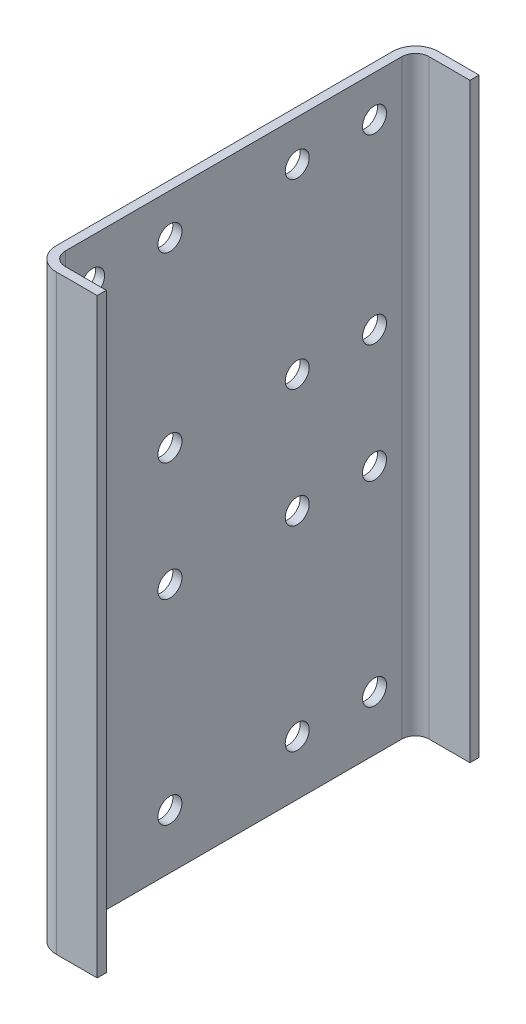
from build123d import *

# Parameters (mm, degrees)
BASE_EXTRUDE_THIN_DEPTH      = 196.85
BASE_EXTRUDE_THIN_DEPTH_BACK = 215.9
SKETCH3_R                    = 8.382
HOLES_DEPTH                  = 258.625377244


with BuildPart() as part:
    # Sketch1 → Base-Extrude-Thin (new, two sides)
    with BuildSketch(Plane(origin=(0, 0, 0), x_dir=(1, 0, 0), z_dir=(0, 1, 0))) as base_extrude_thin_sk:
        with BuildLine():
            Line((44.45, 133.35), (15.875, 133.35))
            ThreePointArc((15.875, 133.35), (4.649679849, 128.700320151), (0, 117.475))
            Line((0, 117.475), (0, 0))
            Line((0, 0), (0, -117.475))
            ThreePointArc((0, -117.475), (4.649679849, -128.700320151), (15.875, -133.35))
            Line((15.875, -133.35), (44.45, -133.35))
            Line((44.45, -133.35), (44.45, -127))
            Line((44.45, -127), (15.875, -127))
            ThreePointArc((15.875, -127), (9.139807909, -124.210192091), (6.35, -117.475))
            Line((6.35, -117.475), (6.35, 0))
            Line((6.35, 0), (6.35, 117.475))
            ThreePointArc((6.35, 117.475), (9.139807909, 124.210192091), (15.875, 127))
            Line((15.875, 127), (44.45, 127))
            Line((44.45, 127), (44.45, 133.35))
        make_face()
    extrude(amount=BASE_EXTRUDE_THIN_DEPTH)
    extrude(base_extrude_thin_sk.sketch, amount=-BASE_EXTRUDE_THIN_DEPTH_BACK)

    # Sketch3 (on Right Plane) → holes (cut, through all)
    with BuildSketch(Plane(origin=(0, 0, 0), x_dir=(0, 0, -1), z_dir=(1, 0, 0))):
        with Locations(Location((44.45, 168.275, 0), (0, 0, 180))):
            Circle(SKETCH3_R)
        with Locations(Location((44.45, 41.275, 0), (0, 0, 180))):
            Circle(SKETCH3_R)
        with Locations(Location((44.45, -41.275, 0), (0, 0, 180))):
            Circle(SKETCH3_R)
        with Locations(Location((44.45, -177.8, 0), (0, 0, 180))):
            Circle(SKETCH3_R)
        with Locations(Location((-44.45, -177.8, 0), (0, 0, 180))):
            Circle(SKETCH3_R)
        with Locations(Location((-98.425, -177.8, 0), (0, 0, 180))):
            Circle(SKETCH3_R)
        with Locations(Location((-98.425, -41.275, 0), (0, 0, 180))):
            Circle(SKETCH3_R)
        with Locations(Location((-44.45, -41.275, 0), (0, 0, 180))):
            Circle(SKETCH3_R)
        with Locations(Location((-44.45, 41.275, 0), (0, 0, 180))):
            Circle(SKETCH3_R)
        with Locations(Location((-98.425, 41.275, 0), (0, 0, 180))):
            Circle(SKETCH3_R)
        with Locations(Location((-98.425, 168.275, 0), (0, 0, 180))):
            Circle(SKETCH3_R)
        with Locations(Location((-44.45, 168.275, 0), (0, 0, 180))):
            Circle(SKETCH3_R)
        with Locations(Location((98.425, -177.8, 0), (0, 0, 180))):
            Circle(SKETCH3_R)
        with Locations(Location((98.425, -41.275, 0), (0, 0, 180))):
            Circle(SKETCH3_R)
        with Locations(Location((98.425, 41.275, 0), (0, 0, 180))):
            Circle(SKETCH3_R)
        with Locations(Location((98.425, 168.275, 0), (0, 0, 180))):
            Circle(SKETCH3_R)
    extrude(amount=HOLES_DEPTH, mode=Mode.SUBTRACT)


solid = part.part
